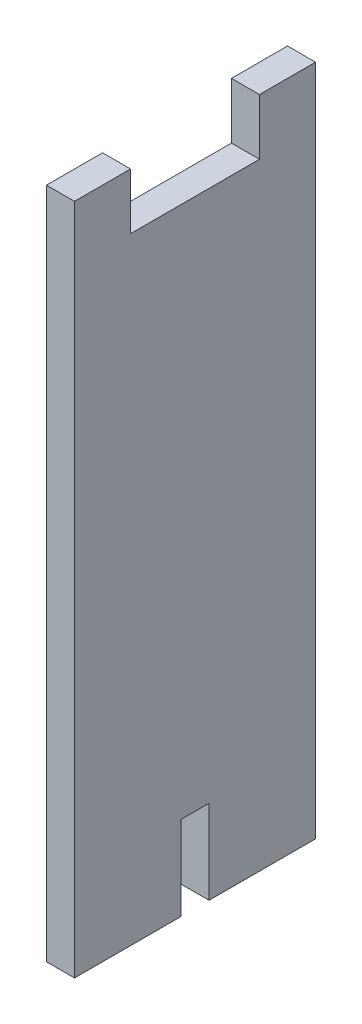
from build123d import *

# Parameters (mm, degrees)
BOSS_EXTRUDE1_DEPTH = 5


with BuildPart() as part:
    # Sketch1 → Boss-Extrude1 (new body)
    with BuildSketch(Plane(origin=(0, 0, 0), x_dir=(0, 0, -1), z_dir=(1, 0, 0))):
        Polygon((-33, 120), (-33, 111.226045358), (-33, 110), (-10, 110), (-10, 111.226045358), (-10, 120), (0, 120), (0, 0), (-19, 0), (-19, 15), (-24, 15), (-24, 0), (-43, 0), (-43, 120), align=None)
    extrude(amount=BOSS_EXTRUDE1_DEPTH)


solid = part.part
